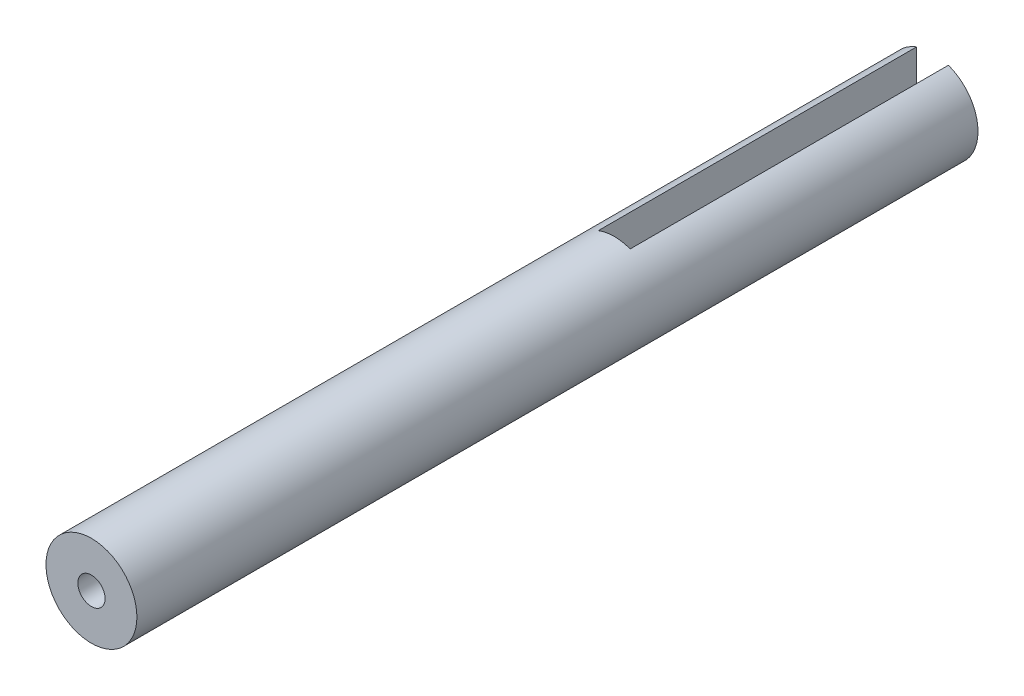
from build123d import *

# Parameters (mm, degrees)
SKETCH1_R           = 10
BOSS_EXTRUDE1_DEPTH = 185
CUT_EXTRUDE1_DEPTH  = 70
SKETCH3_R           = 3
CUT_EXTRUDE2_DEPTH  = 20


with BuildPart() as part:
    # Sketch1 → Boss-Extrude1 (new body)
    with BuildSketch(Plane.XY):
        Circle(SKETCH1_R)
    extrude(amount=BOSS_EXTRUDE1_DEPTH)

    # Sketch1_3 → Cut-Extrude1 (cut)
    with BuildSketch(Plane.XY):
        with BuildLine():
            Line((3.5, -9.367496998), (3.5, 9.367496998))
            ThreePointArc((3.5, 9.367496998), (0, 10), (-3.5, 9.367496998))
            Line((-3.5, 9.367496998), (-3.5, -9.367496998))
            ThreePointArc((-3.5, -9.367496998), (0, -10), (3.5, -9.367496998))
        make_face()
    extrude(amount=CUT_EXTRUDE1_DEPTH, mode=Mode.SUBTRACT)

    # Sketch3 → Cut-Extrude2 (cut)
    with BuildSketch(Plane.XY.offset(185)):
        Circle(SKETCH3_R)
    extrude(amount=-CUT_EXTRUDE2_DEPTH, mode=Mode.SUBTRACT)


solid = part.part
